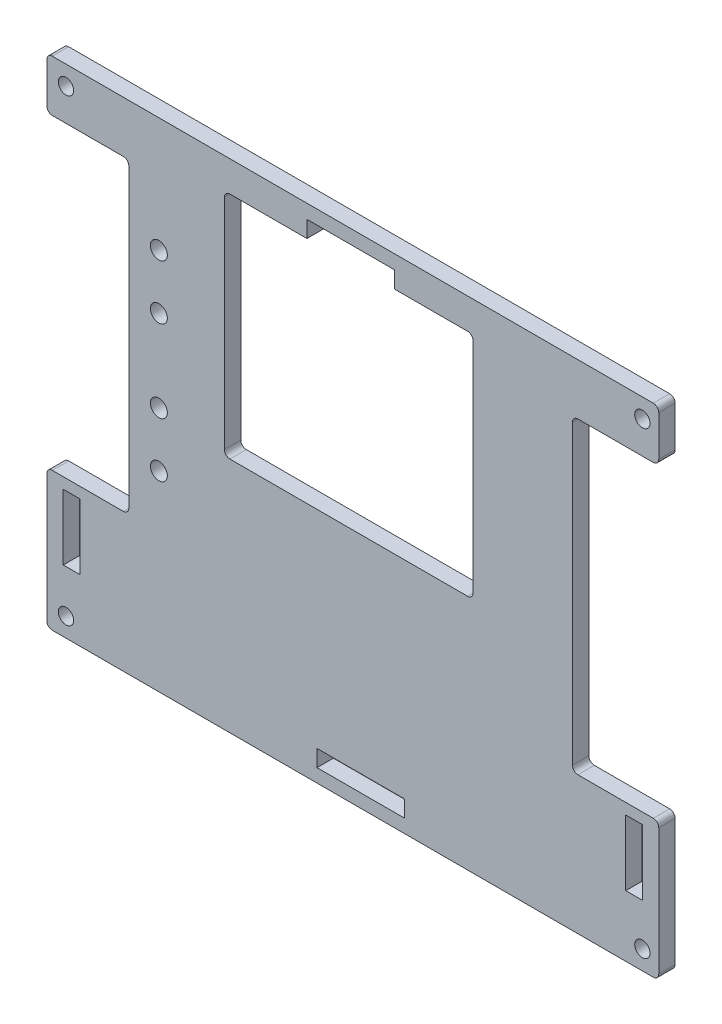
from build123d import *

# Parameters (mm, degrees)
CROQUIS1_R              = 1.55
CROQUIS1_W              = 16
CROQUIS1_H              = 3.05
CROQUIS1_W_2            = 3.05
CROQUIS1_H_2            = 12
SALIENTE_EXTRUIR1_DEPTH = 3
CROQUIS2_R              = 1.4
CORTAR_EXTRUIR2_DEPTH   = 4


with BuildPart() as part:
    # Croquis1 → Saliente-Extruir1 (new body)
    with BuildSketch(Plane.XY):
        with BuildLine():
            Line((56, -21.3), (56, -44.5))
            ThreePointArc((56, -44.5), (55.707106781, -45.207106781), (55, -45.5))
            Line((55, -45.5), (-55, -45.5))
            ThreePointArc((-55, -45.5), (-55.707106781, -45.207106781), (-56, -44.5))
            Line((-56, -44.5), (-56, -21.15))
            ThreePointArc((-56, -21.15), (-55.707106781, -20.442893219), (-55, -20.15))
            Line((-55, -20.15), (-42, -20.15))
            ThreePointArc((-42, -20.15), (-41.292893219, -19.857106781), (-41, -19.15))
            Line((-41, -19.15), (-41, 35.1))
            ThreePointArc((-41, 35.1), (-41.292893219, 35.807106781), (-42, 36.1))
            Line((-42, 36.1), (-55, 36.1))
            ThreePointArc((-55, 36.1), (-55.707106781, 36.392893219), (-56, 37.1))
            Line((-56, 37.1), (-56, 44.5))
            ThreePointArc((-56, 44.5), (-55.707106781, 45.207106781), (-55, 45.5))
            Line((-55, 45.5), (55, 45.5))
            ThreePointArc((55, 45.5), (55.707106781, 45.207106781), (56, 44.5))
            Line((56, 44.5), (56, 37.1))
            ThreePointArc((56, 37.1), (55.707106781, 36.392893219), (55, 36.1))
            Line((55, 36.1), (41.2, 36.1))
            ThreePointArc((41.2, 36.1), (40.492893219, 35.807106781), (40.2, 35.1))
            Line((40.2, 35.1), (40.2, -19.3))
            ThreePointArc((40.2, -19.3), (40.492893219, -20.007106781), (41.2, -20.3))
            Line((41.2, -20.3), (55, -20.3))
            ThreePointArc((55, -20.3), (55.707106781, -20.592893219), (56, -21.3))
        make_face()
        with Locations((-35.5, 24.5)):
            Circle(CROQUIS1_R, mode=Mode.SUBTRACT)
        with Locations((-35.5, 14.5)):
            Circle(CROQUIS1_R, mode=Mode.SUBTRACT)
        with Locations((-35.5, -0.5)):
            Circle(CROQUIS1_R, mode=Mode.SUBTRACT)
        with Locations((-35.5, -10.5)):
            Circle(CROQUIS1_R, mode=Mode.SUBTRACT)
        with BuildLine():
            Line((-8.4, 39.9), (-22.5, 39.9))
            ThreePointArc((-22.5, 39.9), (-23.207106781, 39.607106781), (-23.5, 38.9))
            Line((-23.5, 38.9), (-23.5, -1.1))
            ThreePointArc((-23.5, -1.1), (-23.207106781, -1.807106781), (-22.5, -2.1))
            Line((-22.5, -2.1), (21, -2.1))
            ThreePointArc((21, -2.1), (21.707106781, -1.807106781), (22, -1.1))
            Line((22, -1.1), (22, 38.9))
            ThreePointArc((22, 38.9), (21.707106781, 39.607106781), (21, 39.9))
            Line((21, 39.9), (7.6, 39.9))
            Line((7.6, 39.9), (7.6, 42.95))
            Line((7.6, 42.95), (-8.4, 42.95))
            Line((-8.4, 42.95), (-8.4, 39.9))
        make_face(mode=Mode.SUBTRACT)
        with Locations((1.45, -41.525)):
            Rectangle(CROQUIS1_W, CROQUIS1_H, mode=Mode.SUBTRACT)
        with Locations((51.475, -28.3)):
            Rectangle(CROQUIS1_W_2, CROQUIS1_H_2, mode=Mode.SUBTRACT)
        with Locations((-51.475, -28.15)):
            Rectangle(CROQUIS1_W_2, CROQUIS1_H_2, mode=Mode.SUBTRACT)
    extrude(amount=SALIENTE_EXTRUIR1_DEPTH)

    # Croquis2 → Cortar-Extruir2 (cut, through all)
    with BuildSketch(Plane.XY.offset(3)):
        with Locations((53, 42)):
            Circle(CROQUIS2_R)
        with Locations((-52.5, 42)):
            Circle(CROQUIS2_R)
        with Locations((-52.5, -42)):
            Circle(CROQUIS2_R)
        with Locations((53, -42)):
            Circle(CROQUIS2_R)
    extrude(amount=-CORTAR_EXTRUIR2_DEPTH, mode=Mode.SUBTRACT)


solid = part.part
